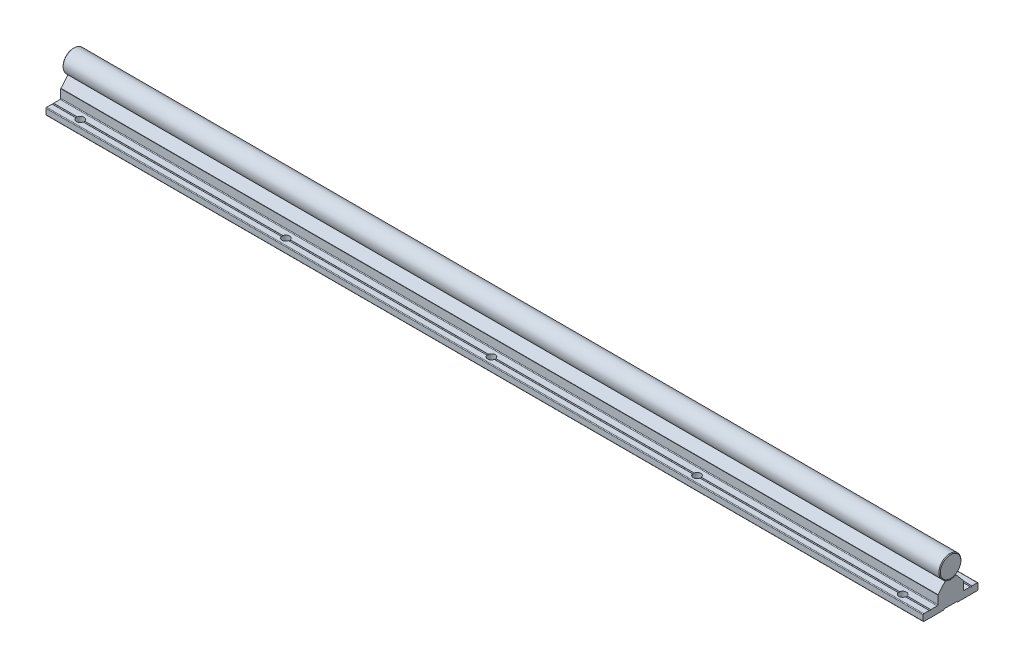
from build123d import *

# Parameters (mm, degrees)
EXTRUDE_2614_DEPTH       = 1500
SKETCH_1_3_R             = 8
EXTRUDE_2743_DEPTH       = 1500
FILLET_4_R               = 0.2
SKETCH_2_R               = 2.75
CUT_EXTRUDE_1_DEPTH      = 6
PATTERN_LINEAR_1_COUNT   = 20
PATTERN_LINEAR_1_PITCH   = 150
PATTERN_LINEAR_2_COUNT   = 20
PATTERN_LINEAR_2_PITCH   = 150
FILLET_1_R               = 0.3
CUT_EXTRUDE_2_DEPTH      = 3
FILLET_2_R               = 0.3
PATTERN_LINEAR_3_COUNT   = 20
PATTERN_LINEAR_3_PITCH   = 150
CHAMFER_1_SIZE           = 0.5
FILLET_3_R               = 0.5
FILLET_5_R               = 0.2
FILLET_6_R               = 0.1
FILLET_7_R               = 0.1
SKETCH_7_W               = 3500
SKETCH_7_H               = 1500
SKETCH_7_W_2             = 640
SKETCH_7_H_2             = 500
CUT_EXTRUDE_3_DEPTH      = 9.0000001
CUT_EXTRUDE_3_DEPTH_BACK = 26.0000001
CHAMFER_2_SIZE           = 0.5


with BuildPart() as part:
    # Sketch 1 → Extrude 2614 (new body, symmetric)
    with BuildSketch(Plane(origin=(0, 0, 0), x_dir=(0, 0, -1), z_dir=(1, 0, 0))):
        Polygon((-20, -25), (-4.75, -25), (-4.75, -24.4), (4.75, -24.4), (4.75, -25), (20, -25), (20, -20), (15.5, -20), (15, -20.5), (14.5, -20), (9.25, -20), (9.25, -13.3), (9.110116754, -13.3), (4, -7.21), (3.8, -7.21), (2.309327639, -7.659439004), (0, -8.355703281), (-2.309327657, -7.659438999), (-3.8, -7.21), (-4, -7.21), (-9.110116754, -13.3), (-9.25, -13.3), (-9.25, -20), (-14.5, -20), (-15, -20.5), (-15.5, -20), (-20, -20), align=None)
    extrude(amount=EXTRUDE_2614_DEPTH, both=True)

    # Fillet 4
    fillet_4_edges = [part.edges().sort_by_distance(p)[0] for p in [
        (0, -20, -15.5),
        (0, -24.4, -4.75),
        (0, -24.4, 4.75),
        (0, -20, 15.5),
        (0, -20, 14.5),
        (0, -8.355703281, 0),
        (0, -20, -14.5),
    ]]
    fillet(fillet_4_edges, radius=FILLET_4_R)

    # Sketch 2 → Cut-Extrude 1 (cut, through all)
    with BuildSketch(Plane(origin=(0, -20, 0), x_dir=(1, 0, 0), z_dir=(0, 1, 0))):
        with Locations((-1425, -15)):
            Circle(SKETCH_2_R)
        with Locations((-1425, 15)):
            Circle(SKETCH_2_R)
        with Locations((-1275, -15)):
            Circle(SKETCH_2_R)
        with Locations((-1275, 15)):
            Circle(SKETCH_2_R)
        with Locations((-1125, -15)):
            Circle(SKETCH_2_R)
        with Locations((-1125, 15)):
            Circle(SKETCH_2_R)
        with Locations((-975, -15)):
            Circle(SKETCH_2_R)
        with Locations((-975, 15)):
            Circle(SKETCH_2_R)
        with Locations((-825, -15)):
            Circle(SKETCH_2_R)
        with Locations((-825, 15)):
            Circle(SKETCH_2_R)
        with Locations((-675, -15)):
            Circle(SKETCH_2_R)
        with Locations((-675, 15)):
            Circle(SKETCH_2_R)
        with Locations((-525, -15)):
            Circle(SKETCH_2_R)
        with Locations((-525, 15)):
            Circle(SKETCH_2_R)
        with Locations((-375, -15)):
            Circle(SKETCH_2_R)
        with Locations((-375, 15)):
            Circle(SKETCH_2_R)
        with Locations((-225, -15)):
            Circle(SKETCH_2_R)
        with Locations((-225, 15)):
            Circle(SKETCH_2_R)
        with Locations((-75, -15)):
            Circle(SKETCH_2_R)
        with Locations((-75, 15)):
            Circle(SKETCH_2_R)
        with Locations((75, -15)):
            Circle(SKETCH_2_R)
        with Locations((75, 15)):
            Circle(SKETCH_2_R)
        with Locations((225, -15)):
            Circle(SKETCH_2_R)
        with Locations((225, 15)):
            Circle(SKETCH_2_R)
        with Locations((375, -15)):
            Circle(SKETCH_2_R)
        with Locations((375, 15)):
            Circle(SKETCH_2_R)
        with Locations((525, -15)):
            Circle(SKETCH_2_R)
        with Locations((525, 15)):
            Circle(SKETCH_2_R)
        with Locations((675, -15)):
            Circle(SKETCH_2_R)
        with Locations((675, 15)):
            Circle(SKETCH_2_R)
        with Locations((825, -15)):
            Circle(SKETCH_2_R)
        with Locations((825, 15)):
            Circle(SKETCH_2_R)
        with Locations((975, -15)):
            Circle(SKETCH_2_R)
        with Locations((975, 15)):
            Circle(SKETCH_2_R)
        with Locations((1125, -15)):
            Circle(SKETCH_2_R)
        with Locations((1125, 15)):
            Circle(SKETCH_2_R)
        with Locations((1275, -15)):
            Circle(SKETCH_2_R)
        with Locations((1275, 15)):
            Circle(SKETCH_2_R)
        with Locations((1425, -15)):
            Circle(SKETCH_2_R)
        with Locations((1425, 15)):
            Circle(SKETCH_2_R)
    extrude(amount=-CUT_EXTRUDE_1_DEPTH, mode=Mode.SUBTRACT)

    # Sketch 3 → Cut-Revolve 1 (revolve, cut)
    with BuildSketch(Plane.XY):
        Polygon((-1425, 0), (-1427.2, -1.270170592), (-1427.2, -7.5), (-1427.75, -7.5), (-1427.75, -19), (-1429.75, -19), (-1429.75, -24.4), (-1425, -24.4), align=None)
    cut_revolve_1 = revolve(axis=Axis((-1425, 56.434869358, 0), (0, -1, 0)), mode=Mode.SUBTRACT)

    # Pattern Linear 1: Cut-Revolve 1 ×20
    with Locations(*[(i * PATTERN_LINEAR_1_PITCH, 0, 0) for i in range(1, PATTERN_LINEAR_1_COUNT)]):
        add(cut_revolve_1, mode=Mode.SUBTRACT)

    # Fillet 3
    fillet_3_edges = [part.edges().sort_by_distance(p)[0] for p in [
        (0, -20, -9.25),
        (0, -20, -20),
        (0, -25, -20),
        (0, -25, -4.75),
        (0, -25, 4.75),
        (0, -20, 9.25),
        (0, -25, 20),
        (0, -20, 20),
    ]]
    fillet(fillet_3_edges, radius=FILLET_3_R)

    # Fillet 5
    fillet_5_edges = [part.edges().sort_by_distance(p)[0] for p in [
        (0, -7.21, 4),
        (0, -7.21, 3.8),
        (0, -7.21, -3.8),
        (0, -7.21, -4),
    ]]
    fillet(fillet_5_edges, radius=FILLET_5_R)

    # Fillet 6
    fillet_6_edges = [part.edges().sort_by_distance(p)[0] for p in [
        (0, -13.3, 9.25),
        (0, -13.3, -9.25),
    ]]
    fillet(fillet_6_edges, radius=FILLET_6_R)

    # Fillet 7
    fillet_7_edges = [part.edges().sort_by_distance(p)[0] for p in [
        (0, -13.3, 9.110116754),
        (0, -13.3, -9.110116754),
    ]]
    fillet(fillet_7_edges, radius=FILLET_7_R)


with BuildPart() as body_2:
    # Sketch 1_3 → Extrude 2743 (new body, symmetric)
    with BuildSketch(Plane(origin=(0, 0, 0), x_dir=(0, 0, -1), z_dir=(1, 0, 0))):
        Circle(SKETCH_1_3_R)
    extrude(amount=EXTRUDE_2743_DEPTH, both=True)

    # Sketch 4 → Cut-Revolve 2 (revolve, cut)
    with BuildSketch(Plane.XY):
        Polygon((-1425, -10), (-1427.2, -10), (-1427.2, -1.270170592), (-1425, 0), align=None)
    cut_revolve_2 = revolve(axis=Axis((-1425, 39.840222878, 0), (0, -1, 0)), mode=Mode.SUBTRACT)

    # Pattern Linear 2: Cut-Revolve 2 ×20
    with Locations(*[(i * PATTERN_LINEAR_2_PITCH, 0, 0) for i in range(1, PATTERN_LINEAR_2_COUNT)]):
        add(cut_revolve_2, mode=Mode.SUBTRACT)

    # Chamfer 1
    chamfer_1_edges = [body_2.edges().sort_by_distance(p)[0] for p in [
        (-1500, 0, 8),
        (1500, 0, 8),
    ]]
    chamfer(chamfer_1_edges, length=CHAMFER_1_SIZE)


with BuildPart() as body_3:
    # Sketch 5 → Revolve 1 (revolve)
    with BuildSketch(Plane.XY):
        Polygon((-1425, -24), (-1429.5, -24), (-1429.5, -19), (-1427.5, -19), (-1427.5, -2.461880215), (-1426.7, -2), (-1425, -2), align=None)
    revolve(axis=Axis((-1425, 35.529626596, 0), (0, -1, 0)))

    # Fillet 1
    fillet_1_edges = [body_3.edges().sort_by_distance(p)[0] for p in [
        (-1420.5, -19, 0),
    ]]
    fillet(fillet_1_edges, radius=FILLET_1_R)

    # Sketch 6 → Cut-Extrude 2 (cut)
    with BuildSketch(Plane.XZ.offset(24)):
        Polygon((-1423.25, -1.010362971), (-1423.25, 1.010362971), (-1425, 2.020725942), (-1426.75, 1.010362971), (-1426.75, -1.010362971), (-1425, -2.020725942), align=None)
    extrude(amount=-CUT_EXTRUDE_2_DEPTH, mode=Mode.SUBTRACT)

    # Fillet 2
    fillet_2_edges = [body_3.edges().sort_by_distance(p)[0] for p in [
        (-1424.125, -24, -1.515544457),
        (-1423.25, -24, 0),
        (-1424.125, -24, 1.515544457),
        (-1425.875, -24, 1.515544457),
        (-1426.75, -24, 0),
        (-1425.875, -24, -1.515544457),
        (-1420.5, -24, 0),
    ]]
    fillet(fillet_2_edges, radius=FILLET_2_R)


with BuildPart() as pattern_linear_3_1:
    # Pattern Linear 3: pattern copy
    add(body_3.part.moved(Location(Vector(1, 0, 0) * (1 * PATTERN_LINEAR_3_PITCH))))


with BuildPart() as pattern_linear_3_2:
    # Pattern Linear 3: pattern copy
    add(body_3.part.moved(Location(Vector(1, 0, 0) * (2 * PATTERN_LINEAR_3_PITCH))))


with BuildPart() as pattern_linear_3_3:
    # Pattern Linear 3: pattern copy
    add(body_3.part.moved(Location(Vector(1, 0, 0) * (3 * PATTERN_LINEAR_3_PITCH))))


with BuildPart() as pattern_linear_3_4:
    # Pattern Linear 3: pattern copy
    add(body_3.part.moved(Location(Vector(1, 0, 0) * (4 * PATTERN_LINEAR_3_PITCH))))


with BuildPart() as pattern_linear_3_5:
    # Pattern Linear 3: pattern copy
    add(body_3.part.moved(Location(Vector(1, 0, 0) * (5 * PATTERN_LINEAR_3_PITCH))))


with BuildPart() as pattern_linear_3_6:
    # Pattern Linear 3: pattern copy
    add(body_3.part.moved(Location(Vector(1, 0, 0) * (6 * PATTERN_LINEAR_3_PITCH))))


with BuildPart() as pattern_linear_3_7:
    # Pattern Linear 3: pattern copy
    add(body_3.part.moved(Location(Vector(1, 0, 0) * (7 * PATTERN_LINEAR_3_PITCH))))


with BuildPart() as pattern_linear_3_8:
    # Pattern Linear 3: pattern copy
    add(body_3.part.moved(Location(Vector(1, 0, 0) * (8 * PATTERN_LINEAR_3_PITCH))))


with BuildPart() as pattern_linear_3_9:
    # Pattern Linear 3: pattern copy
    add(body_3.part.moved(Location(Vector(1, 0, 0) * (9 * PATTERN_LINEAR_3_PITCH))))


with BuildPart() as pattern_linear_3_10:
    # Pattern Linear 3: pattern copy
    add(body_3.part.moved(Location(Vector(1, 0, 0) * (10 * PATTERN_LINEAR_3_PITCH))))


with BuildPart() as pattern_linear_3_11:
    # Pattern Linear 3: pattern copy
    add(body_3.part.moved(Location(Vector(1, 0, 0) * (11 * PATTERN_LINEAR_3_PITCH))))


with BuildPart() as pattern_linear_3_12:
    # Pattern Linear 3: pattern copy
    add(body_3.part.moved(Location(Vector(1, 0, 0) * (12 * PATTERN_LINEAR_3_PITCH))))


with BuildPart() as pattern_linear_3_13:
    # Pattern Linear 3: pattern copy
    add(body_3.part.moved(Location(Vector(1, 0, 0) * (13 * PATTERN_LINEAR_3_PITCH))))


with BuildPart() as pattern_linear_3_14:
    # Pattern Linear 3: pattern copy
    add(body_3.part.moved(Location(Vector(1, 0, 0) * (14 * PATTERN_LINEAR_3_PITCH))))


with BuildPart() as pattern_linear_3_15:
    # Pattern Linear 3: pattern copy
    add(body_3.part.moved(Location(Vector(1, 0, 0) * (15 * PATTERN_LINEAR_3_PITCH))))


with BuildPart() as pattern_linear_3_16:
    # Pattern Linear 3: pattern copy
    add(body_3.part.moved(Location(Vector(1, 0, 0) * (16 * PATTERN_LINEAR_3_PITCH))))


with BuildPart() as pattern_linear_3_17:
    # Pattern Linear 3: pattern copy
    add(body_3.part.moved(Location(Vector(1, 0, 0) * (17 * PATTERN_LINEAR_3_PITCH))))


with BuildPart() as pattern_linear_3_18:
    # Pattern Linear 3: pattern copy
    add(body_3.part.moved(Location(Vector(1, 0, 0) * (18 * PATTERN_LINEAR_3_PITCH))))


with BuildPart() as pattern_linear_3_19:
    # Pattern Linear 3: pattern copy
    add(body_3.part.moved(Location(Vector(1, 0, 0) * (19 * PATTERN_LINEAR_3_PITCH))))


with BuildPart() as cut_extrude_3_tool:
    # Sketch 7 → Cut-Extrude 3 (new body, two sides)
    with BuildSketch(Plane(origin=(0, 0, 0), x_dir=(1, 0, 0), z_dir=(0, 1, 0))) as cut_extrude_3_sk:
        Rectangle(SKETCH_7_W, SKETCH_7_H)
        with Locations((1125, 0)):
            Rectangle(SKETCH_7_W_2, SKETCH_7_H_2, mode=Mode.SUBTRACT)
    extrude(amount=CUT_EXTRUDE_3_DEPTH)
    extrude(cut_extrude_3_sk.sketch, amount=-CUT_EXTRUDE_3_DEPTH_BACK)


with BuildPart() as part_1:
    add(part.part)

    # Cut-Extrude 3: cut by cut_extrude_3_tool
    add(cut_extrude_3_tool.part, mode=Mode.SUBTRACT)


with BuildPart() as body_2_1:
    add(body_2.part)

    # Cut-Extrude 3: cut by cut_extrude_3_tool
    add(cut_extrude_3_tool.part, mode=Mode.SUBTRACT)

    # Chamfer 2
    chamfer_2_edges = [body_2_1.edges().sort_by_distance(p)[0] for p in [
        (805, 0, 8),
        (1445, 0, 8),
    ]]
    chamfer(chamfer_2_edges, length=CHAMFER_2_SIZE)


with BuildPart() as body_3_1:
    add(body_3.part)

    # Cut-Extrude 3: cut by cut_extrude_3_tool
    add(cut_extrude_3_tool.part, mode=Mode.SUBTRACT)


with BuildPart() as pattern_linear_3_1_1:
    add(pattern_linear_3_1.part)

    # Cut-Extrude 3: cut by cut_extrude_3_tool
    add(cut_extrude_3_tool.part, mode=Mode.SUBTRACT)


with BuildPart() as pattern_linear_3_2_1:
    add(pattern_linear_3_2.part)

    # Cut-Extrude 3: cut by cut_extrude_3_tool
    add(cut_extrude_3_tool.part, mode=Mode.SUBTRACT)


with BuildPart() as pattern_linear_3_3_1:
    add(pattern_linear_3_3.part)

    # Cut-Extrude 3: cut by cut_extrude_3_tool
    add(cut_extrude_3_tool.part, mode=Mode.SUBTRACT)


with BuildPart() as pattern_linear_3_4_1:
    add(pattern_linear_3_4.part)

    # Cut-Extrude 3: cut by cut_extrude_3_tool
    add(cut_extrude_3_tool.part, mode=Mode.SUBTRACT)


with BuildPart() as pattern_linear_3_5_1:
    add(pattern_linear_3_5.part)

    # Cut-Extrude 3: cut by cut_extrude_3_tool
    add(cut_extrude_3_tool.part, mode=Mode.SUBTRACT)


with BuildPart() as pattern_linear_3_6_1:
    add(pattern_linear_3_6.part)

    # Cut-Extrude 3: cut by cut_extrude_3_tool
    add(cut_extrude_3_tool.part, mode=Mode.SUBTRACT)


with BuildPart() as pattern_linear_3_7_1:
    add(pattern_linear_3_7.part)

    # Cut-Extrude 3: cut by cut_extrude_3_tool
    add(cut_extrude_3_tool.part, mode=Mode.SUBTRACT)


with BuildPart() as pattern_linear_3_8_1:
    add(pattern_linear_3_8.part)

    # Cut-Extrude 3: cut by cut_extrude_3_tool
    add(cut_extrude_3_tool.part, mode=Mode.SUBTRACT)


with BuildPart() as pattern_linear_3_9_1:
    add(pattern_linear_3_9.part)

    # Cut-Extrude 3: cut by cut_extrude_3_tool
    add(cut_extrude_3_tool.part, mode=Mode.SUBTRACT)


with BuildPart() as pattern_linear_3_10_1:
    add(pattern_linear_3_10.part)

    # Cut-Extrude 3: cut by cut_extrude_3_tool
    add(cut_extrude_3_tool.part, mode=Mode.SUBTRACT)


with BuildPart() as pattern_linear_3_11_1:
    add(pattern_linear_3_11.part)

    # Cut-Extrude 3: cut by cut_extrude_3_tool
    add(cut_extrude_3_tool.part, mode=Mode.SUBTRACT)


with BuildPart() as pattern_linear_3_12_1:
    add(pattern_linear_3_12.part)

    # Cut-Extrude 3: cut by cut_extrude_3_tool
    add(cut_extrude_3_tool.part, mode=Mode.SUBTRACT)


with BuildPart() as pattern_linear_3_13_1:
    add(pattern_linear_3_13.part)

    # Cut-Extrude 3: cut by cut_extrude_3_tool
    add(cut_extrude_3_tool.part, mode=Mode.SUBTRACT)


with BuildPart() as pattern_linear_3_14_1:
    add(pattern_linear_3_14.part)

    # Cut-Extrude 3: cut by cut_extrude_3_tool
    add(cut_extrude_3_tool.part, mode=Mode.SUBTRACT)


solid = Compound([pattern_linear_3_15.part, pattern_linear_3_16.part, pattern_linear_3_17.part, pattern_linear_3_18.part, pattern_linear_3_19.part, part_1.part, body_2_1.part])
